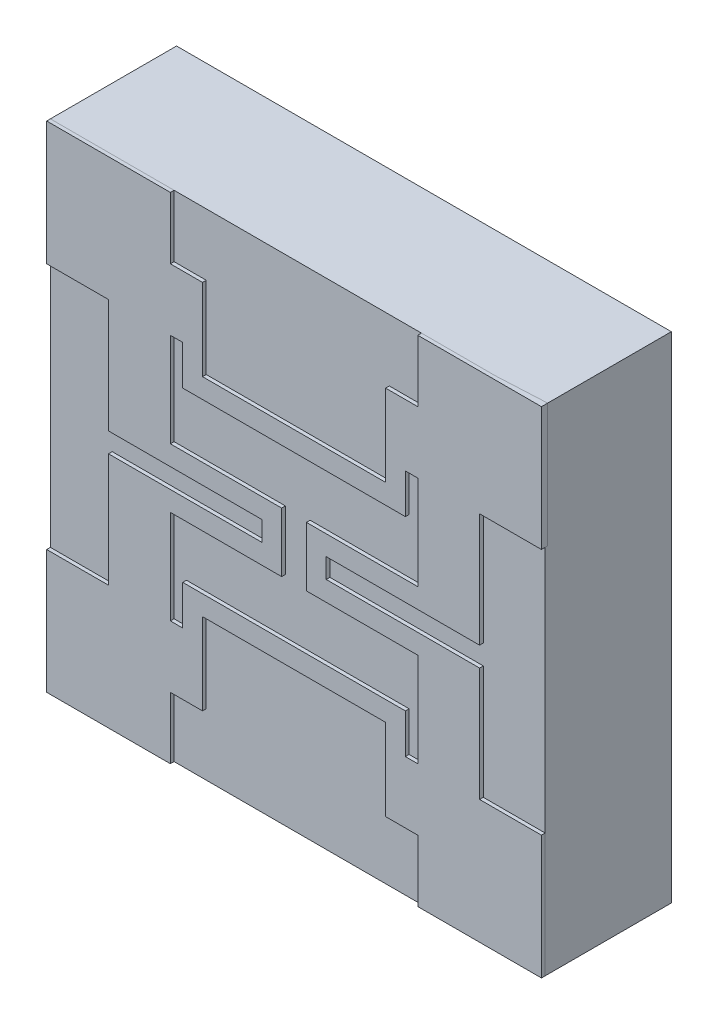
from build123d import *

# Parameters (mm, degrees)
WAFER_W             = 2
WAFER_H             = 2
BOSS_EXTRUDE3_DEPTH = 0.5
SIN_LAYER_W         = 2
SIN_LAYER_H         = 2
BOSS_EXTRUDE4_DEPTH = 0.01
BOSS_EXTRUDE5_DEPTH = 0.025
TOP_MEMBRANE_W      = 0.9
TOP_MEMBRANE_H      = 1
BOTTOM_W            = 1.96151
BOTTOM_H            = 1.96151


with BuildPart() as part:
    # wafer → Boss-Extrude3 (new body)
    with BuildSketch(Plane.XY):
        Rectangle(WAFER_W, WAFER_H)
    extrude(amount=-BOSS_EXTRUDE3_DEPTH)

    # SiN Layer → Boss-Extrude4 (add)
    with BuildSketch(Plane.XY):
        Rectangle(SIN_LAYER_W, SIN_LAYER_H)
    extrude(amount=BOSS_EXTRUDE4_DEPTH)

    # top membrane → Cut-Loft8 section 0
    with BuildSketch(Plane.XY):
        Rectangle(TOP_MEMBRANE_W, TOP_MEMBRANE_H)
    # bottom → Cut-Loft8 section 1
    with BuildSketch(Plane.XY.offset(-0.5)):
        Rectangle(BOTTOM_W, BOTTOM_H)
    loft(mode=Mode.SUBTRACT)


with BuildPart() as body_2:
    # circuit → Boss-Extrude5 (new body)
    with BuildSketch(Plane.XY):
        Polygon((-1, 1), (-0.5, 1), (-0.5, 0.75), (-0.37, 0.75), (-0.37, 0.42), (0.37, 0.42), (0.37, 0.75), (0.5, 0.75), (0.5, 1), (1, 1), (1, 0.5), (0.75, 0.5), (0.75, 0.04), (0.13, 0.04), (0.13, -0.04), (0.75, -0.04), (0.75, -0.5), (1, -0.5), (1, -1), (0.5, -1), (0.5, -0.75), (0.37, -0.75), (0.37, -0.42), (-0.37, -0.42), (-0.37, -0.75), (-0.5, -0.75), (-0.5, -1), (-1, -1), (-1, -0.5), (-0.75, -0.5), (-0.75, -0.04), (-0.13, -0.04), (-0.13, 0.04), (-0.75, 0.04), (-0.75, 0.5), (-1, 0.5), align=None)
        Polygon((-0.45, 0.5), (-0.5, 0.5), (-0.5, 0.12), (-0.05, 0.12), (-0.05, -0.12), (-0.5, -0.12), (-0.5, -0.5), (-0.45, -0.5), (-0.45, -0.34), (0.45, -0.34), (0.45, -0.5), (0.5, -0.5), (0.5, -0.12), (0.05, -0.12), (0.05, 0.12), (0.5, 0.12), (0.5, 0.5), (0.45, 0.5), (0.45, 0.34), (-0.45, 0.34), align=None, mode=Mode.SUBTRACT)
    extrude(amount=BOSS_EXTRUDE5_DEPTH)


solid = Compound([part.part, body_2.part])
